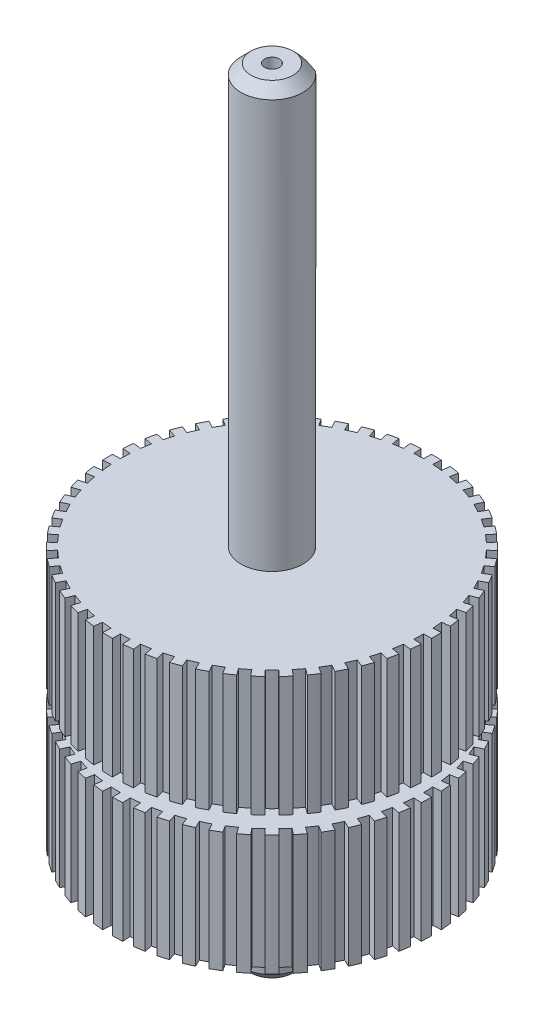
from build123d import *

# Parameters (mm, degrees)
SKETCH_1_R               = 12.89
EXTRUDE_1_DEPTH          = 10.4
SKETCH_2_R               = 2.5
EXTRUDE_2_DEPTH          = 33.8
SKETCH_3_R               = 2.5
EXTRUDE_3_DEPTH          = 8.2
SKETCH_5_W               = 3
SKETCH_5_H               = 1.4
CUT_EXTRUDE_1_DEPTH      = 9.7
PATTERN_CIRCULAR_1_COUNT = 50
CUT_EXTRUDE_2_DEPTH      = 9.7
PATTERN_CIRCULAR_2_COUNT = 50
SKETCH_7_R               = 0.6
CUT_EXTRUDE_3_DEPTH      = 4
SKETCH_8_R               = 0.6
CUT_EXTRUDE_4_DEPTH      = 4
CHAMFER_1_SIZE           = 0.8
CUT_EXTRUDE_5_DEPTH      = 18


with BuildPart() as part:
    # Эскиз1 → Бобышка-Вытянуть1 (new body, symmetric)
    with BuildSketch(Plane(origin=(0, 0, 0), x_dir=(1, 0, 0), z_dir=(0, 1, 0))):
        Circle(SKETCH_1_R)
    extrude(amount=EXTRUDE_1_DEPTH, both=True)

    # Эскиз2 → Бобышка-Вытянуть2 (add)
    with BuildSketch(Plane(origin=(0, 10.4, 0), x_dir=(1, 0, 0), z_dir=(0, 1, 0))):
        Circle(SKETCH_2_R)
    extrude(amount=EXTRUDE_2_DEPTH)

    # Эскиз3 → Бобышка-Вытянуть3 (add)
    with BuildSketch(Plane.XZ.offset(10.4)):
        Circle(SKETCH_3_R)
    extrude(amount=EXTRUDE_3_DEPTH)

    # Эскиз5 → Вырез-Повернуть1 (revolve, cut)
    with BuildSketch(Plane.XY):
        with Locations((-11.39, 0)):
            Rectangle(SKETCH_5_W, SKETCH_5_H)
    revolve(axis=Axis((0, 0, 0), (0, -1, 0)), mode=Mode.SUBTRACT)

    # Эскиз4 → Вырез-Вытянуть1 (cut)
    with BuildSketch(Plane(origin=(0, 10.4, 0), x_dir=(1, 0, 0), z_dir=(0, 1, 0))):
        with BuildLine():
            Line((0.769183864, 12.225827423), (0.809369797, 12.864564529))
            ThreePointArc((0.809369797, 12.864564529), (1.213056159, 12.832793724), (1.615545381, 12.7883585))
            Line((1.615545381, 12.7883585), (1.535332111, 12.153405091))
            ThreePointArc((1.535332111, 12.153405091), (1.152826838, 12.195634066), (0.769183864, 12.225827423))
        make_face()
    cut_extrude_1 = extrude(amount=-CUT_EXTRUDE_1_DEPTH, mode=Mode.SUBTRACT)

    # Круговой массив1: Вырез-Вытянуть1 ×50 about axis
    pattern_circular_1_axis = Axis((0, 0, 0), (0, 1, 0))
    for i in range(1, PATTERN_CIRCULAR_1_COUNT):
        add(cut_extrude_1.rotate(pattern_circular_1_axis, i * 360 / PATTERN_CIRCULAR_1_COUNT), mode=Mode.SUBTRACT)

    # Эскиз6 → Вырез-Вытянуть2 (cut)
    with BuildSketch(Plane.XZ.offset(10.4)):
        with BuildLine():
            Line((0, -12.25), (0, -12.89))
            ThreePointArc((0, -12.89), (0.404884685, -12.883639563), (0.809369797, -12.864564529))
            Line((0.809369797, -12.864564529), (0.769183864, -12.225827423))
            ThreePointArc((0.769183864, -12.225827423), (0.384781799, -12.243955364), (0, -12.25))
        make_face()
    cut_extrude_2 = extrude(amount=-CUT_EXTRUDE_2_DEPTH, mode=Mode.SUBTRACT)

    # Круговой массив2: Вырез-Вытянуть2 ×50 about axis
    pattern_circular_2_axis = Axis((0, 0, 0), (0, 1, 0))
    for i in range(1, PATTERN_CIRCULAR_2_COUNT):
        add(cut_extrude_2.rotate(pattern_circular_2_axis, i * 360 / PATTERN_CIRCULAR_2_COUNT), mode=Mode.SUBTRACT)

    # Эскиз7 → Вырез-Вытянуть3 (cut)
    with BuildSketch(Plane(origin=(0, 44.2, 0), x_dir=(1, 0, 0), z_dir=(0, 1, 0))):
        Circle(SKETCH_7_R)
    extrude(amount=-CUT_EXTRUDE_3_DEPTH, mode=Mode.SUBTRACT)

    # Эскиз8 → Вырез-Вытянуть4 (cut)
    with BuildSketch(Plane.XZ.offset(18.6)):
        Circle(SKETCH_8_R)
    extrude(amount=-CUT_EXTRUDE_4_DEPTH, mode=Mode.SUBTRACT)

    # Фаска1
    chamfer_1_edges = [part.edges().sort_by_distance(p)[0] for p in [
        (-2.5, -18.6, 0),
        (-2.5, 44.2, 0),
    ]]
    chamfer(chamfer_1_edges, length=CHAMFER_1_SIZE)

    # Эскиз9 → Вырез-Вытянуть5 (cut)
    with BuildSketch(Plane(origin=(0, 44.2, 0), x_dir=(1, 0, 0), z_dir=(0, 1, 0))):
        with BuildLine():
            Line((-1.5, 2), (1.5, 2))
            ThreePointArc((1.5, 2), (0, 2.5), (-1.5, 2))
        make_face()
    extrude(amount=-CUT_EXTRUDE_5_DEPTH, mode=Mode.SUBTRACT)


solid = part.part
